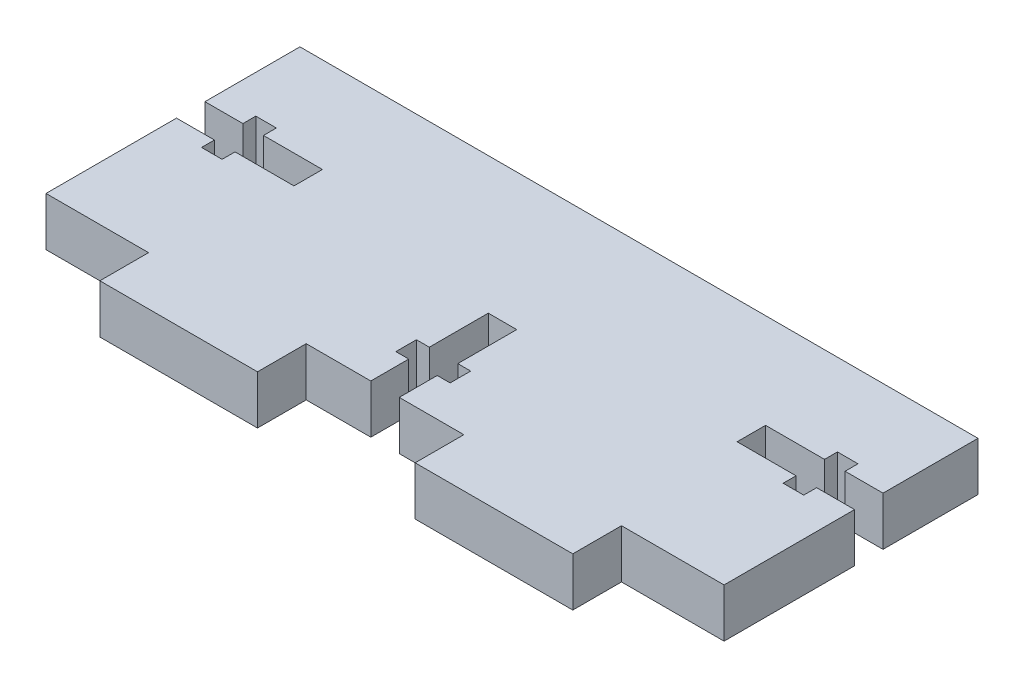
from build123d import *

# Parameters (mm, degrees)
BOSS_EXTRUDE4_DEPTH = 5.13


with BuildPart() as part:
    # Sketch2 → Boss-Extrude4 (new body)
    with BuildSketch(Plane(origin=(0, 0, 0), x_dir=(1, 0, 0), z_dir=(0, 1, 0))):
        Polygon((48.771774494, 3.748783209), (59.571774494, 3.748783209), (59.571774494, 17.490283209), (55.576774494, 17.490283209), (55.576774494, 16.131283196), (53.409774494, 16.131283196), (53.409774494, 17.490283196), (47.202774494, 17.490283196), (47.202774494, 20.487283196), (53.409774494, 20.487283196), (53.409774494, 21.846283196), (55.576774494, 21.846283196), (55.576774494, 20.487281812), (59.571774494, 20.487281812), (59.571774494, 30.487281812), (-11.828225506, 30.487281812), (-11.828225506, 20.487281812), (-7.833225506, 20.4872818), (-7.833225506, 21.846280998), (-5.666225506, 21.846280998), (-5.666225506, 20.487280998), (0.540774494, 20.487280998), (0.540774494, 17.490280998), (-5.666225506, 17.490280998), (-5.666225506, 16.131280998), (-7.833225506, 16.131280998), (-7.833225506, 17.490283995), (-11.828225506, 17.490283209), (-11.828225506, 3.748783209), (-1.028225506, 3.748783209), (-1.028225506, -1.381216791), (15.571774494, -1.381216791), (15.571774494, 3.748783209), (22.373274494, 3.748783209), (22.373274494, 7.743783209), (21.014274494, 7.743783209), (21.014274494, 9.910783209), (22.373274494, 9.910783209), (22.373274494, 16.117783209), (25.370274494, 16.117783209), (25.370274494, 9.910783209), (26.729274494, 9.910783209), (26.729274494, 7.743783209), (25.370274494, 7.743783209), (25.370274494, 3.748783209), (32.171774494, 3.748783209), (32.171774494, -1.381216791), (48.771774494, -1.381216791), align=None)
    extrude(amount=BOSS_EXTRUDE4_DEPTH)


solid = part.part
